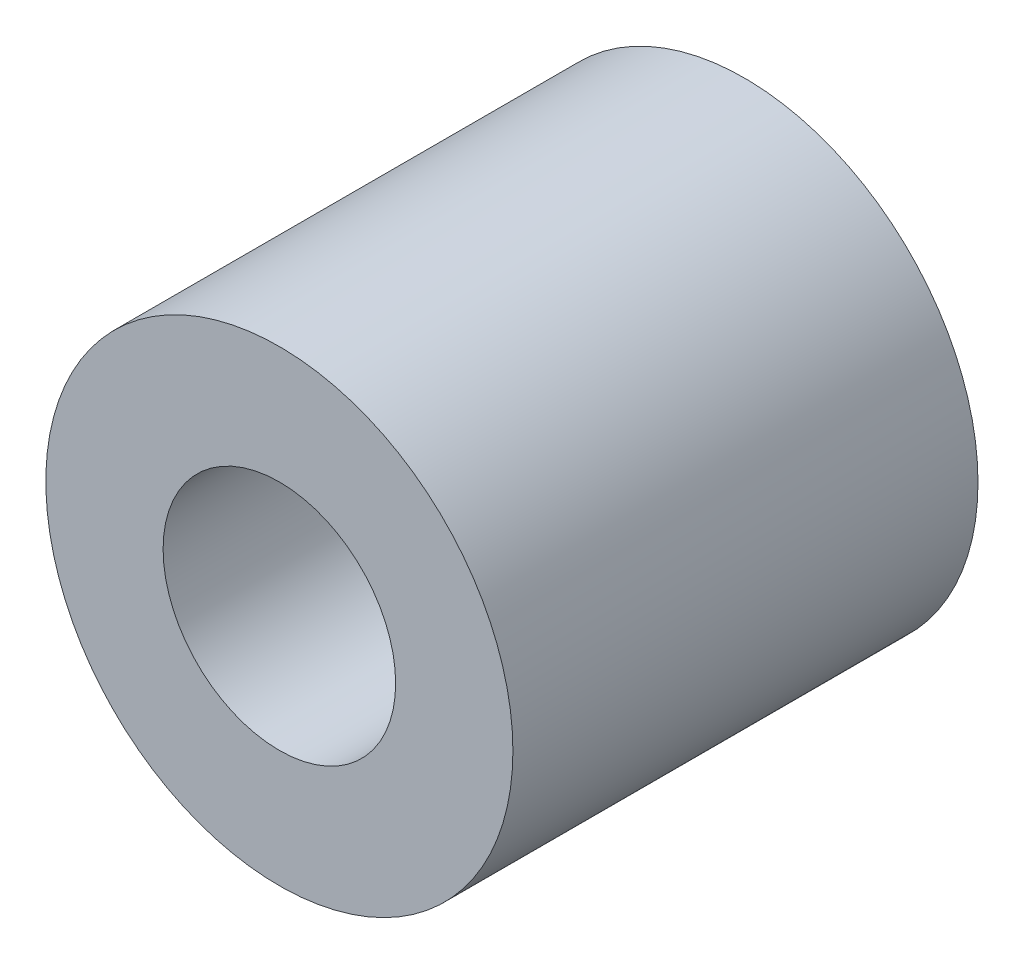
from build123d import *

# Parameters (mm, degrees)
SKETCH3_R                = 6.0255
SKETCH3_R_2              = 3
BOSS_EXTRUDE1_DEPTH      = 6
BOSS_EXTRUDE1_DEPTH_BACK = 6


with BuildPart() as part:
    # Sketch3 → Boss-Extrude1 (new body, two sides)
    with BuildSketch(Plane.XY) as boss_extrude1_sk:
        Circle(SKETCH3_R)
        Circle(SKETCH3_R_2, mode=Mode.SUBTRACT)
    extrude(amount=BOSS_EXTRUDE1_DEPTH)
    extrude(boss_extrude1_sk.sketch, amount=-BOSS_EXTRUDE1_DEPTH_BACK)


solid = part.part
